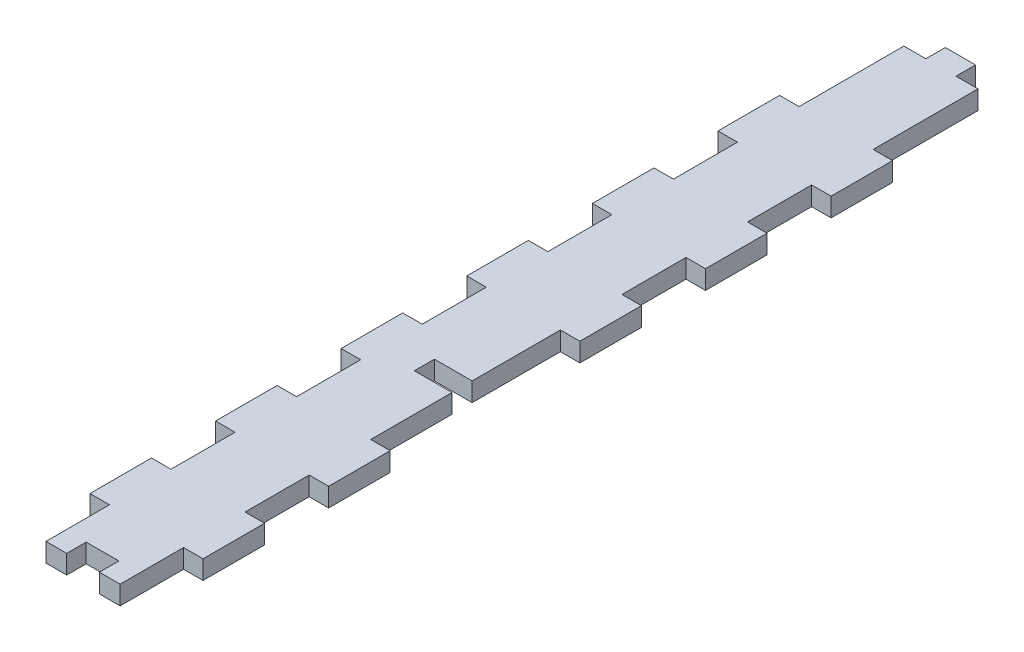
from build123d import *

# Parameters (mm, degrees)
SKETCH1_W           = 18
SKETCH1_H           = 139.694434203
BOSS_EXTRUDE1_DEPTH = 3
SKETCH4_W           = 3.2
SKETCH4_H           = 10.2
SKETCH4_W_2         = 5.2
SKETCH4_H_2         = 3.2
CUT_EXTRUDE2_DEPTH  = 4


with BuildPart() as part:
    # Sketch1 → Boss-Extrude1 (new body)
    with BuildSketch(Plane(origin=(0, 0, 0), x_dir=(1, 0, 0), z_dir=(0, 1, 0))):
        with Locations((0, -69.847217102)):
            Rectangle(SKETCH1_W, SKETCH1_H)
    extrude(amount=-BOSS_EXTRUDE1_DEPTH)

    # Sketch4 → Cut-Extrude2 (cut, through all)
    with BuildSketch(Plane(origin=(0, 0, 0), x_dir=(1, 0, 0), z_dir=(0, 1, 0))):
        Polygon((5.9, -19.794434203), (9.1, -19.794434203), (9.1, 0.1), (2.4, 0.1), (2.4, -3.1), (5.9, -3.1), align=None)
        with Locations((7.5, -54.694434203)):
            Rectangle(SKETCH4_W, SKETCH4_H)
        with Locations((7.5, -34.694434203)):
            Rectangle(SKETCH4_W, SKETCH4_H)
        with Locations((7.5, -134.694434203)):
            Rectangle(SKETCH4_W, SKETCH4_H)
        with Locations((7.5, -114.694434203)):
            Rectangle(SKETCH4_W, SKETCH4_H)
        with Locations((-7.5, -54.694434203)):
            Rectangle(SKETCH4_W, SKETCH4_H)
        with Locations((-7.5, -114.694434203)):
            Rectangle(SKETCH4_W, SKETCH4_H)
        with Locations((-7.5, -74.694434203)):
            Rectangle(SKETCH4_W, SKETCH4_H)
        with Locations((-7.5, -134.694434203)):
            Rectangle(SKETCH4_W, SKETCH4_H)
        with Locations((-7.5, -34.694434203)):
            Rectangle(SKETCH4_W, SKETCH4_H)
        with Locations((-7.5, -94.694434203)):
            Rectangle(SKETCH4_W, SKETCH4_H)
        Polygon((5.9, -83.644434203), (-0.1, -83.644434203), (-0.1, -86.844434203), (5.9, -86.844434203), (5.9, -99.794434203), (9.1, -99.794434203), (9.1, -69.594434203), (5.9, -69.594434203), align=None)
        with Locations((0, -138.194434203)):
            Rectangle(SKETCH4_W_2, SKETCH4_H_2)
        Polygon((-9.1, 0.1), (-9.1, -19.794434203), (-5.9, -19.794434203), (-5.9, -3.1), (-2.4, -3.1), (-2.4, 0.1), align=None)
    extrude(amount=-CUT_EXTRUDE2_DEPTH, mode=Mode.SUBTRACT)


solid = part.part
